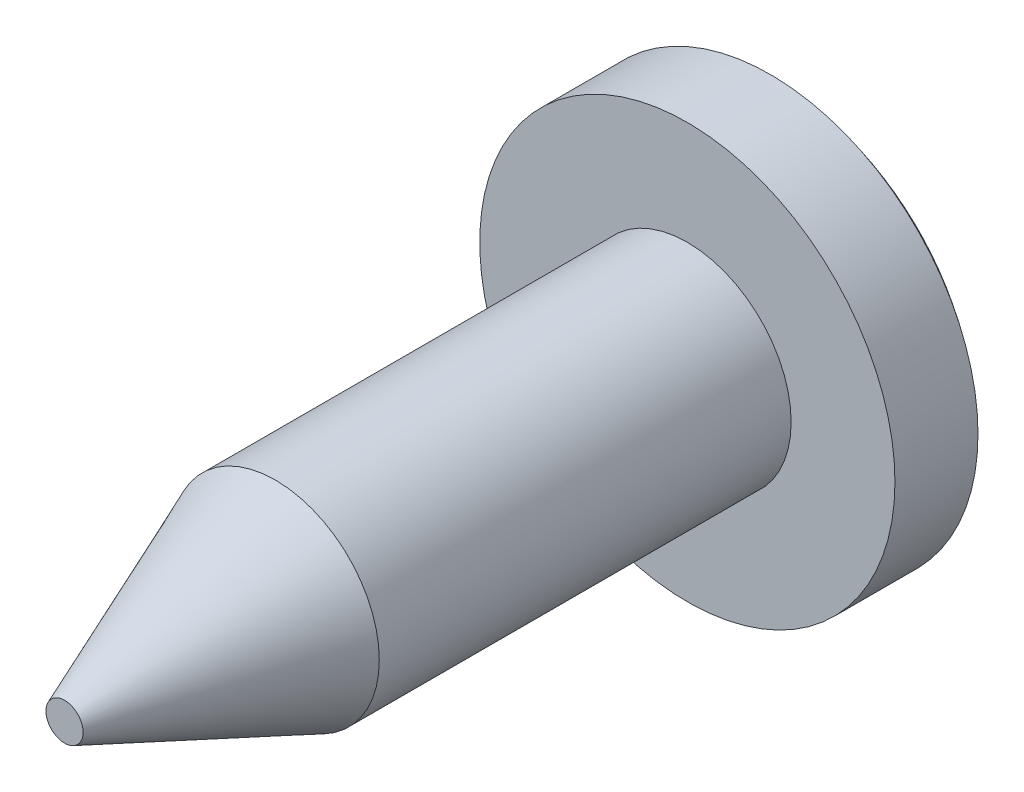
from build123d import *

# Parameters (mm, degrees)
SKETCH2_W      = 0.6
SKETCH2_H      = 1.518456807
EXTRUDE1_DEPTH = 1.27
SKETCH3_W      = 1.103174595
SKETCH3_H      = 0.588939024
EXTRUDE2_DEPTH = 1.27
CHAMFER1_SIZE  = 2.032
CHAMFER1_SIZE2 = 0.820981291


with BuildPart() as part:
    # Sketch1 → Revolve1 (revolve)
    with BuildSketch(Plane(origin=(0, 0, 0), x_dir=(1, 0, 0), z_dir=(0, 1, 0))):
        with BuildLine():
            Line((0, 0), (0, 7.5))
            ThreePointArc((0, 7.5), (1.059481005, 7.319945729), (2, 6.8))
            Line((2, 6.8), (2, 6))
            Line((2, 6), (1, 6))
            Line((1, 6), (1, 0))
            Line((1, 0), (0, 0))
        make_face()
    revolve(axis=Axis((0, 0, 0), (0, 0, -1)))

    # Sketch2 → Extrude1 (cut, symmetric)
    with BuildSketch(Plane(origin=(0, 0, 0), x_dir=(1, 0, 0), z_dir=(0, 1, 0))):
        with Locations((0, 7.559228404)):
            Rectangle(SKETCH2_W, SKETCH2_H)
    extrude(amount=EXTRUDE1_DEPTH, both=True, mode=Mode.SUBTRACT)

    # Sketch3 → Extrude2 (cut, symmetric)
    with BuildSketch(Plane(origin=(0, 0, 0), x_dir=(0, 0, -1), z_dir=(1, 0, 0))):
        with Locations((7.351587298, 0)):
            Rectangle(SKETCH3_W, SKETCH3_H)
    extrude(amount=EXTRUDE2_DEPTH, both=True, mode=Mode.SUBTRACT)

    # Chamfer1
    chamfer1_edges = [part.edges().sort_by_distance(p)[0] for p in [
        (-1, 0, 0),
    ]]
    chamfer1_side = [part.faces().sort_by_distance(p)[0] for p in [
        (-1, 0, -3),
    ]]
    chamfer(chamfer1_edges, length=CHAMFER1_SIZE, length2=CHAMFER1_SIZE2, reference=chamfer1_side[0])


solid = part.part
